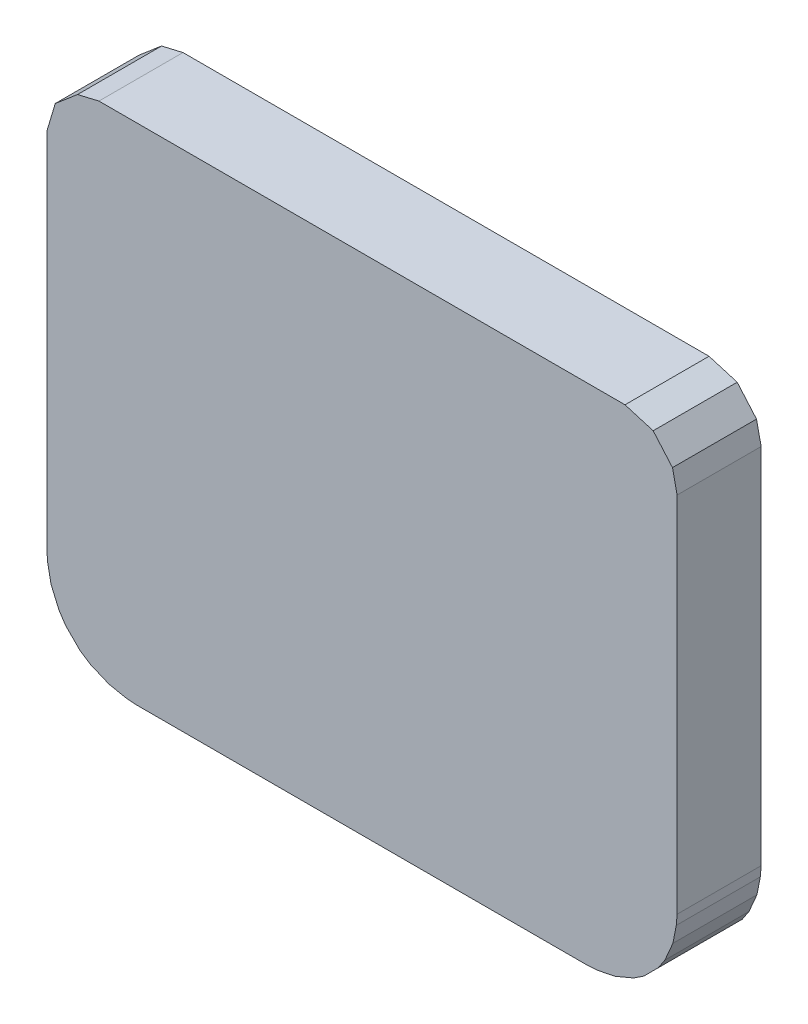
from build123d import *

# Parameters (mm, degrees)
BOSS_EXTRUDE1_DEPTH   = 0.2
BOSS_EXTRUDE1_2_DEPTH = 0.2


with BuildPart() as part:
    # Model → Boss-Extrude1 (new body)
    with BuildSketch(Plane.XY):
        Polygon((-25.753693147, -3.046), (-25.644493147, -3.06), (-25.613193147, -3.068), (-25.522793147, -3.106), (-25.494793147, -3.122), (-25.417093147, -3.182), (-25.394193147, -3.205), (-25.334593147, -3.282), (-25.318493147, -3.31), (-25.280993147, -3.401), (-25.272593147, -3.432), (-25.258193147, -3.541), (-25.257693147, -3.549), (-25.257693147, -4.045), (-25.234893147, -4.16), (-25.169993147, -4.257), (-25.068993147, -4.325), (-25.023993147, -4.379), (-25.013993147, -4.428), (-25.017993147, -6.466), (-25.037993147, -6.533), (-25.073993147, -6.569), (-25.169993147, -6.633), (-25.234893147, -6.73), (-25.257693147, -6.845), (-25.257693147, -7.341), (-25.258193147, -7.349), (-25.272593147, -7.458), (-25.280993147, -7.49), (-25.318393147, -7.58), (-25.334593147, -7.608), (-25.394193147, -7.686), (-25.417093147, -7.709), (-25.494693147, -7.768), (-25.522793147, -7.784), (-25.613193147, -7.822), (-25.644493147, -7.83), (-25.753693147, -7.845), (-25.761793147, -7.845), (-27.953593147, -7.845), (-27.961693147, -7.845), (-28.070893147, -7.83), (-28.102193147, -7.822), (-28.192593147, -7.784), (-28.220693147, -7.768), (-28.298293147, -7.709), (-28.321193147, -7.686), (-28.380793147, -7.608), (-28.396993147, -7.58), (-28.434393147, -7.49), (-28.442793147, -7.458), (-28.457193147, -7.349), (-28.457693147, -7.341), (-28.457693147, -3.549), (-28.457193147, -3.541), (-28.442793147, -3.432), (-28.434393147, -3.401), (-28.396893147, -3.31), (-28.380793147, -3.282), (-28.321193147, -3.205), (-28.298293147, -3.182), (-28.220593147, -3.122), (-28.192593147, -3.106), (-28.102193147, -3.068), (-28.070893147, -3.06), (-27.961693147, -3.046), (-27.953593147, -3.045), (-25.761793147, -3.045), align=None)
    extrude(amount=BOSS_EXTRUDE1_DEPTH)


with BuildPart() as body_2:
    # Model → Boss-Extrude1 2 (new body)
    with BuildSketch(Plane.XY):
        Polygon((0.067006853, -0.02), (0.113006853, -0.073), (0.124006853, -0.124), (0.124006853, -0.988), (0.122006853, -1.012), (0.114006853, -1.053), (0.095006853, -1.097), (0.079006853, -1.121), (0.045006853, -1.155), (0.021006853, -1.171), (-0.023993147, -1.19), (-0.063993147, -1.198), (-0.087993147, -1.2), (-1.163993147, -1.2), (-1.187993147, -1.198), (-1.227993147, -1.19), (-1.272993147, -1.171), (-1.296993147, -1.155), (-1.330993147, -1.121), (-1.346993147, -1.097), (-1.365993147, -1.053), (-1.373993147, -1.012), (-1.375993147, -0.988), (-1.375993147, -0.124), (-1.355993147, -0.057), (-1.302993147, -0.012), (-1.251993147, 0), (6.853e-06, 0), align=None)
    extrude(amount=BOSS_EXTRUDE1_2_DEPTH)


solid = body_2.part
